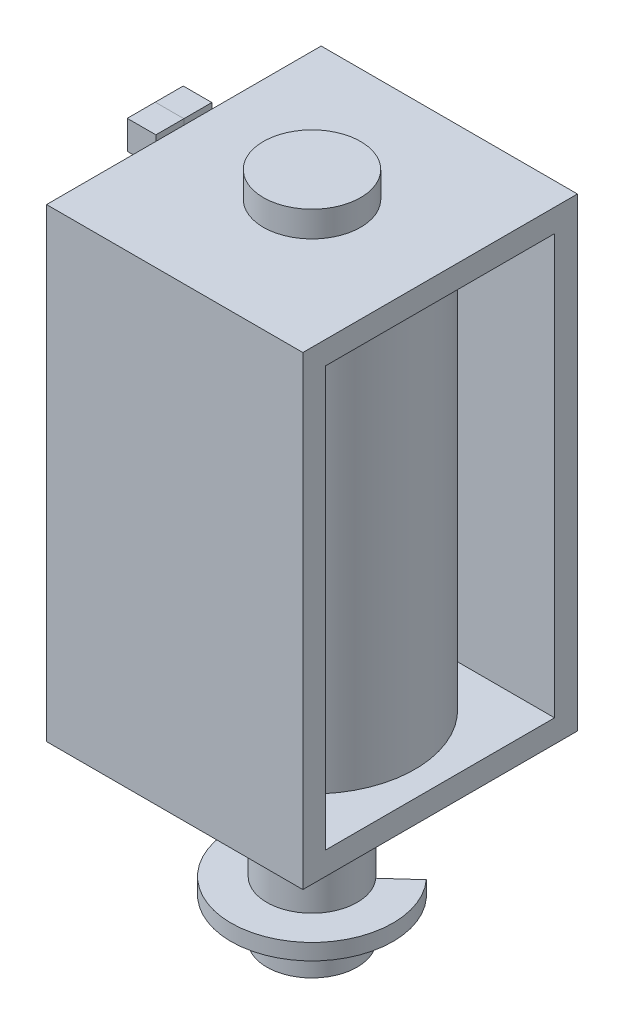
from build123d import *

# Parameters (mm, degrees)
SKETCH3_W            = 12.192
SKETCH3_H            = 20.6502
SKETCH3_W_2          = 10.16
SKETCH3_H_2          = 18.6182
BOSS_EXTRUDE3_DEPTH  = 5.6896
SKETCH2_R            = 4.572
BOSS_EXTRUDE2_DEPTH  = 9.398
SKETCH4_R            = 2.159
BOSS_EXTRUDE4_DEPTH  = 1.143
SKETCH5_R            = 2.0066
BOSS_EXTRUDE5_DEPTH  = 7.874
BOSS_EXTRUDE11_DEPTH = 0.7112
SKETCH7_W            = 1.242870129
SKETCH7_H            = 1.27
BOSS_EXTRUDE12_DEPTH = 1.27
SKETCH7_3_W          = 1.242870129
SKETCH7_3_H          = 1.27
BOSS_EXTRUDE13_DEPTH = 1.27


with BuildPart() as part:
    # Sketch3 → Boss-Extrude3 (new, symmetric)
    with BuildSketch(Plane(origin=(0, 0, 0), x_dir=(0, 0, -1), z_dir=(1, 0, 0))):
        Rectangle(SKETCH3_W, SKETCH3_H)
        Rectangle(SKETCH3_W_2, SKETCH3_H_2, mode=Mode.SUBTRACT)
    extrude(amount=BOSS_EXTRUDE3_DEPTH, both=True)

    # Sketch2 → Boss-Extrude2 (add, symmetric)
    with BuildSketch(Plane(origin=(0, 0, 0), x_dir=(1, 0, 0), z_dir=(0, 1, 0))):
        Circle(SKETCH2_R)
    extrude(amount=BOSS_EXTRUDE2_DEPTH, both=True)

    # Sketch5 → Boss-Extrude5 (add)
    with BuildSketch(Plane.XZ.offset(10.3251)):
        Circle(SKETCH5_R)
    extrude(amount=BOSS_EXTRUDE5_DEPTH)

    # Sketch6 → Boss-Extrude11 (add)
    with BuildSketch(Plane.XZ.offset(15.7099)):
        with BuildLine():
            Line((-2.667, -2.409287407), (-1.488996466, -1.345114524))
            ThreePointArc((-1.488996466, -1.345114524), (0, 2.0066), (1.488996466, -1.345114524))
            Line((1.488996466, -1.345114524), (2.667, -2.409287407))
            ThreePointArc((2.667, -2.409287407), (0, 3.5941), (-2.667, -2.409287407))
        make_face()
    extrude(amount=BOSS_EXTRUDE11_DEPTH)


with BuildPart() as body_2:
    # Sketch4 → Boss-Extrude4 (new body)
    with BuildSketch(Plane(origin=(0, 10.3251, 0), x_dir=(1, 0, 0), z_dir=(0, 1, 0))):
        Circle(SKETCH4_R)
    extrude(amount=BOSS_EXTRUDE4_DEPTH)


with BuildPart() as body_3:
    # Sketch7 → Boss-Extrude12 (new body)
    with BuildSketch(Plane.ZY.offset(5.6896)):
        with Locations((-0.621435065, 9.9441)):
            Rectangle(SKETCH7_W, SKETCH7_H)
    extrude(amount=BOSS_EXTRUDE12_DEPTH)


with BuildPart() as body_4:
    # Sketch7_3 → Boss-Extrude13 (new body)
    with BuildSketch(Plane.ZY.offset(5.6896)):
        with Locations((0.621435065, 9.9441)):
            Rectangle(SKETCH7_3_W, SKETCH7_3_H)
    extrude(amount=BOSS_EXTRUDE13_DEPTH)


solid = Compound([part.part, body_2.part, body_3.part, body_4.part])
